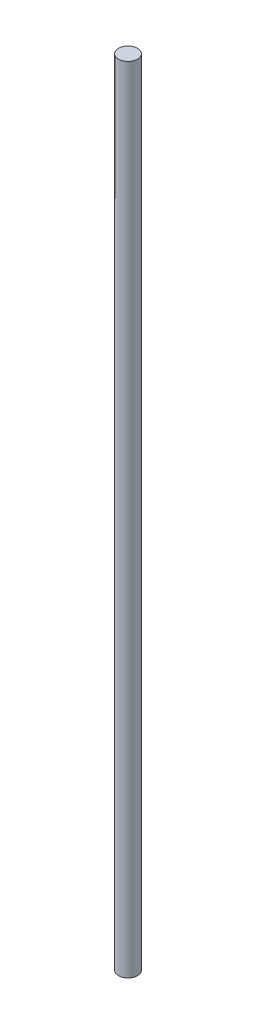
from build123d import *

# Parameters (mm, degrees)
SKETCH1_R           = 2.555
BOSS_EXTRUDE1_DEPTH = 214


with BuildPart() as part:
    # Sketch1 → Boss-Extrude1 (new body)
    with BuildSketch(Plane(origin=(0, 0, 0), x_dir=(1, 0, 0), z_dir=(0, 1, 0))):
        Circle(SKETCH1_R)
    extrude(amount=BOSS_EXTRUDE1_DEPTH)


solid = part.part
